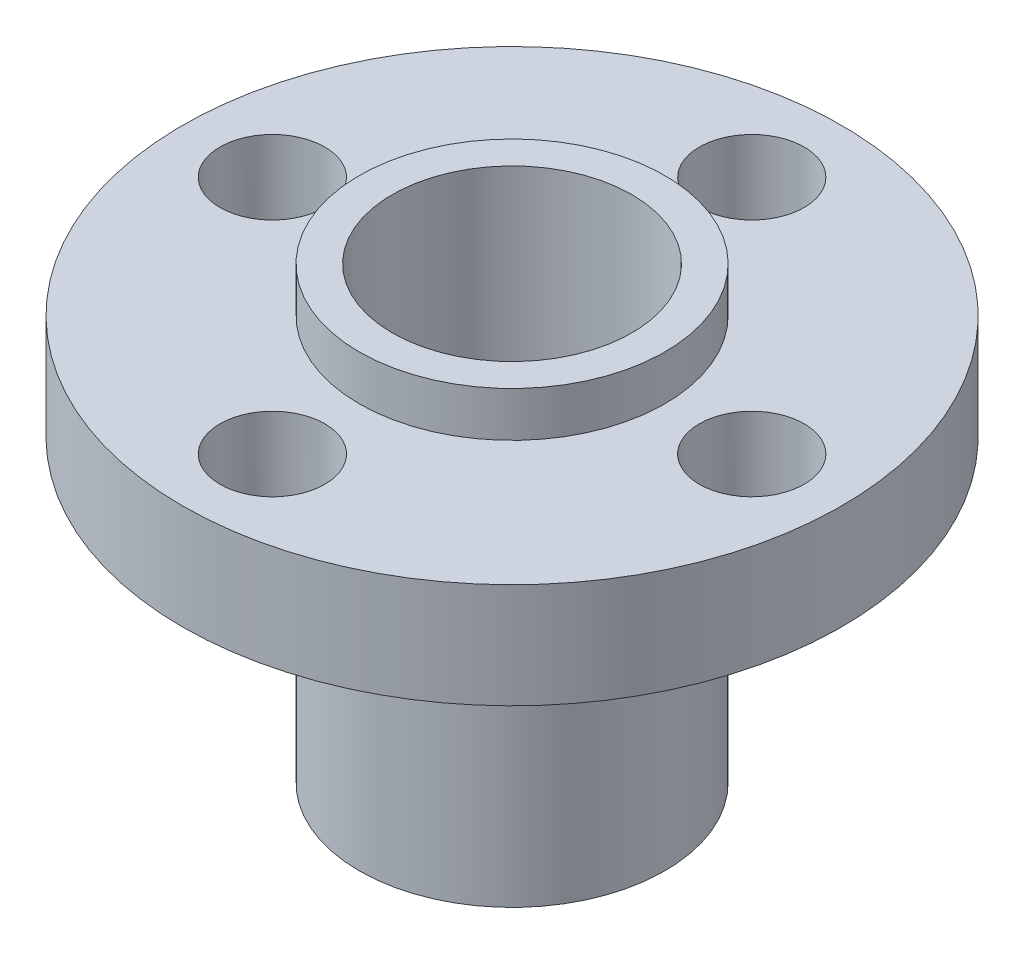
from build123d import *

# Parameters (mm, degrees)
ESBO_O1_R                     = 11
RESSALTO_EXTRUS_O1_DEPTH      = 3.5
ESBO_O2_R                     = 5.1
RESSALTO_EXTRUS_O2_DEPTH      = 1.5
RESSALTO_EXTRUS_O2_DEPTH_BACK = 13.5
ESBO_O3_R                     = 4
CORTE_EXTRUS_O1_DEPTH         = 16
ESBO_O4_R                     = 1.75
CORTE_EXTRUS_O2_DEPTH         = 14.5
PADR_OCIRCULAR1_COUNT         = 4


with BuildPart() as part:
    # Esboço1 → Ressalto-extrusão1 (new body)
    with BuildSketch(Plane(origin=(0, 0, 0), x_dir=(1, 0, 0), z_dir=(0, 1, 0))):
        Circle(ESBO_O1_R)
    extrude(amount=RESSALTO_EXTRUS_O1_DEPTH)

    # Esboço2 → Ressalto-extrusão2 (add, two sides)
    with BuildSketch(Plane(origin=(0, 3.5, 0), x_dir=(1, 0, 0), z_dir=(0, 1, 0))) as ressalto_extrus_o2_sk:
        Circle(ESBO_O2_R)
    extrude(amount=RESSALTO_EXTRUS_O2_DEPTH)
    extrude(ressalto_extrus_o2_sk.sketch, amount=-RESSALTO_EXTRUS_O2_DEPTH_BACK)

    # Esboço3 → Corte-extrusão1 (cut, through all)
    with BuildSketch(Plane(origin=(0, 5, 0), x_dir=(1, 0, 0), z_dir=(0, 1, 0))):
        Circle(ESBO_O3_R)
    extrude(amount=-CORTE_EXTRUS_O1_DEPTH, mode=Mode.SUBTRACT)

    # Esboço4 → Corte-extrusão2 (cut, through all)
    with BuildSketch(Plane(origin=(0, 3.5, 0), x_dir=(1, 0, 0), z_dir=(0, 1, 0))):
        with Locations((0, 8)):
            Circle(ESBO_O4_R)
    corte_extrus_o2 = extrude(amount=-CORTE_EXTRUS_O2_DEPTH, mode=Mode.SUBTRACT)

    # PadrãoCircular1: Corte-extrusão2 ×4 about axis
    padr_ocircular1_axis = Axis((0, 0, 0), (0, 1, 0))
    for i in range(1, PADR_OCIRCULAR1_COUNT):
        add(corte_extrus_o2.rotate(padr_ocircular1_axis, i * 360 / PADR_OCIRCULAR1_COUNT), mode=Mode.SUBTRACT)


solid = part.part
